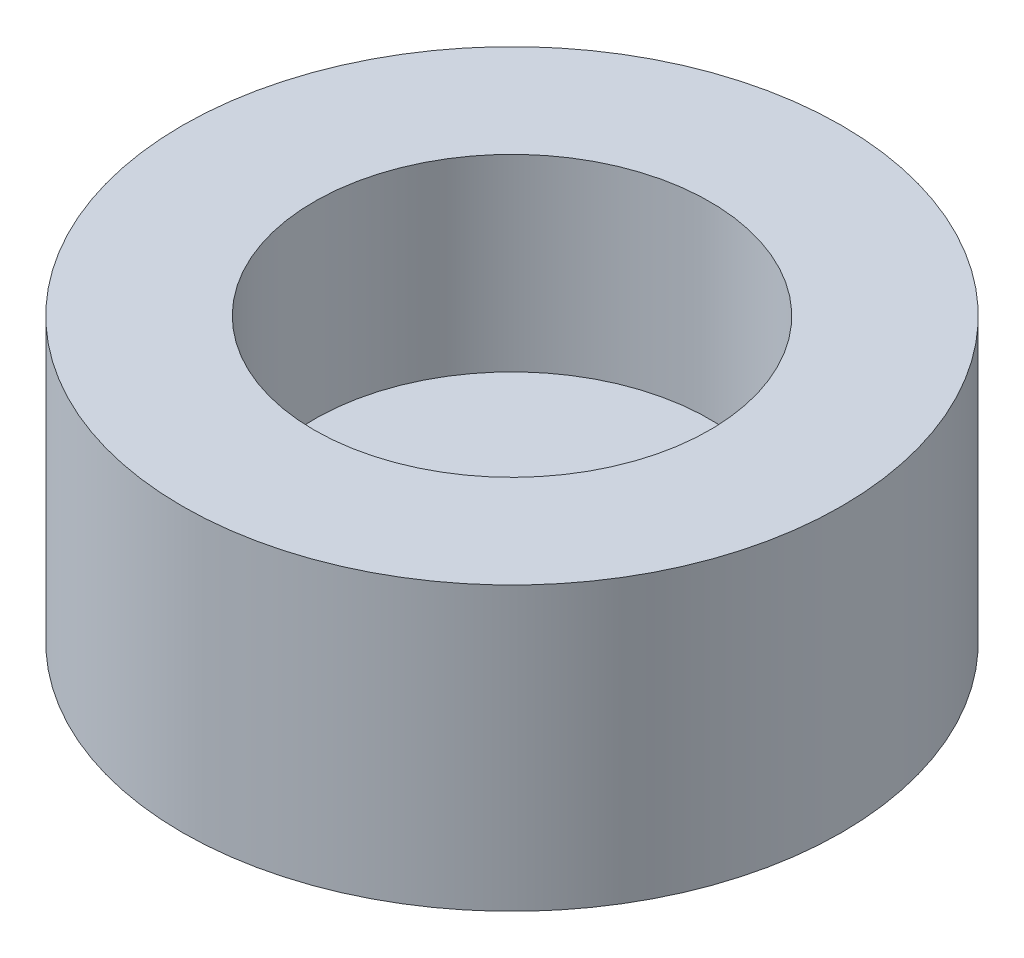
from build123d import *

# Parameters (mm, degrees)
SKETCH1_R           = 3.5
BOSS_EXTRUDE1_DEPTH = 3
SKETCH2_R           = 2.1
CUT_EXTRUDE1_DEPTH  = 2


with BuildPart() as part:
    # Sketch1 → Boss-Extrude1 (new body)
    with BuildSketch(Plane(origin=(0, 0, 0), x_dir=(1, 0, 0), z_dir=(0, 1, 0))):
        Circle(SKETCH1_R)
    extrude(amount=BOSS_EXTRUDE1_DEPTH)

    # Sketch2 → Cut-Extrude1 (cut)
    with BuildSketch(Plane(origin=(0, 3, 0), x_dir=(1, 0, 0), z_dir=(0, 1, 0))):
        Circle(SKETCH2_R)
    extrude(amount=-CUT_EXTRUDE1_DEPTH, mode=Mode.SUBTRACT)


solid = part.part
